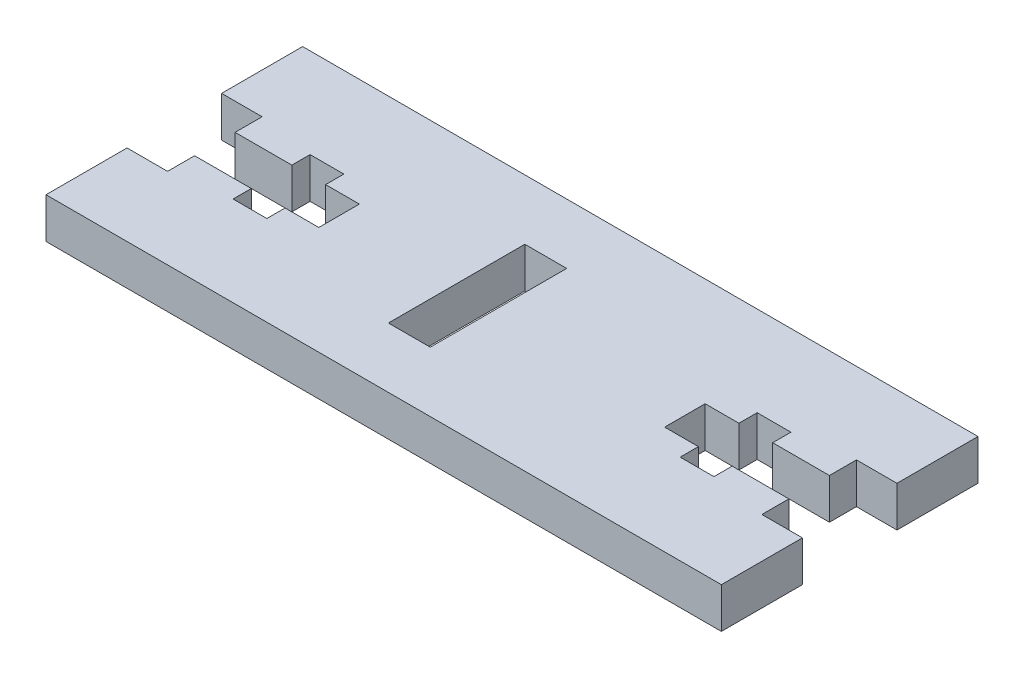
from build123d import *

# Parameters (mm, degrees)
SKETCH2_W           = 50
SKETCH2_H           = 19
BOSS_EXTRUDE1_DEPTH = 3
CUT_EXTRUDE1_DEPTH  = 4
SKETCH4_W           = 3.1
SKETCH4_H           = 10.1
CUT_EXTRUDE2_DEPTH  = 4


with BuildPart() as part:
    # Sketch2 → Boss-Extrude1 (new body)
    with BuildSketch(Plane(origin=(0, 0, 0), x_dir=(1, 0, 0), z_dir=(0, 1, 0))):
        with Locations((25, 9.5)):
            Rectangle(SKETCH2_W, SKETCH2_H)
    extrude(amount=BOSS_EXTRUDE1_DEPTH)

    # Sketch3 → Cut-Extrude1 (cut, through all)
    with BuildSketch(Plane(origin=(0, 3, 0), x_dir=(1, 0, 0), z_dir=(0, 1, 0))):
        Polygon((0, 13), (3, 13), (3, 11), (7.2, 11), (7.2, 12.35), (9.7, 12.35), (9.7, 11), (12.2, 11), (12.2, 8), (9.7, 8), (9.7, 6.65), (7.2, 6.65), (7.2, 8), (3, 8), (3, 6), (0, 6), align=None)
    cut_extrude1 = extrude(amount=-CUT_EXTRUDE1_DEPTH, mode=Mode.SUBTRACT)

    # Mirror1: Cut-Extrude1 across plane
    add(cut_extrude1.mirror(Plane(origin=(25, 0, 0), x_dir=(0, 0, 1), z_dir=(1, 0, 0))), mode=Mode.SUBTRACT)

    # Sketch4 → Cut-Extrude2 (cut, through all)
    with BuildSketch(Plane(origin=(0, 3, 0), x_dir=(1, 0, 0), z_dir=(0, 1, 0))):
        with Locations((22.45, 9.5)):
            Rectangle(SKETCH4_W, SKETCH4_H)
    extrude(amount=-CUT_EXTRUDE2_DEPTH, mode=Mode.SUBTRACT)


solid = part.part
